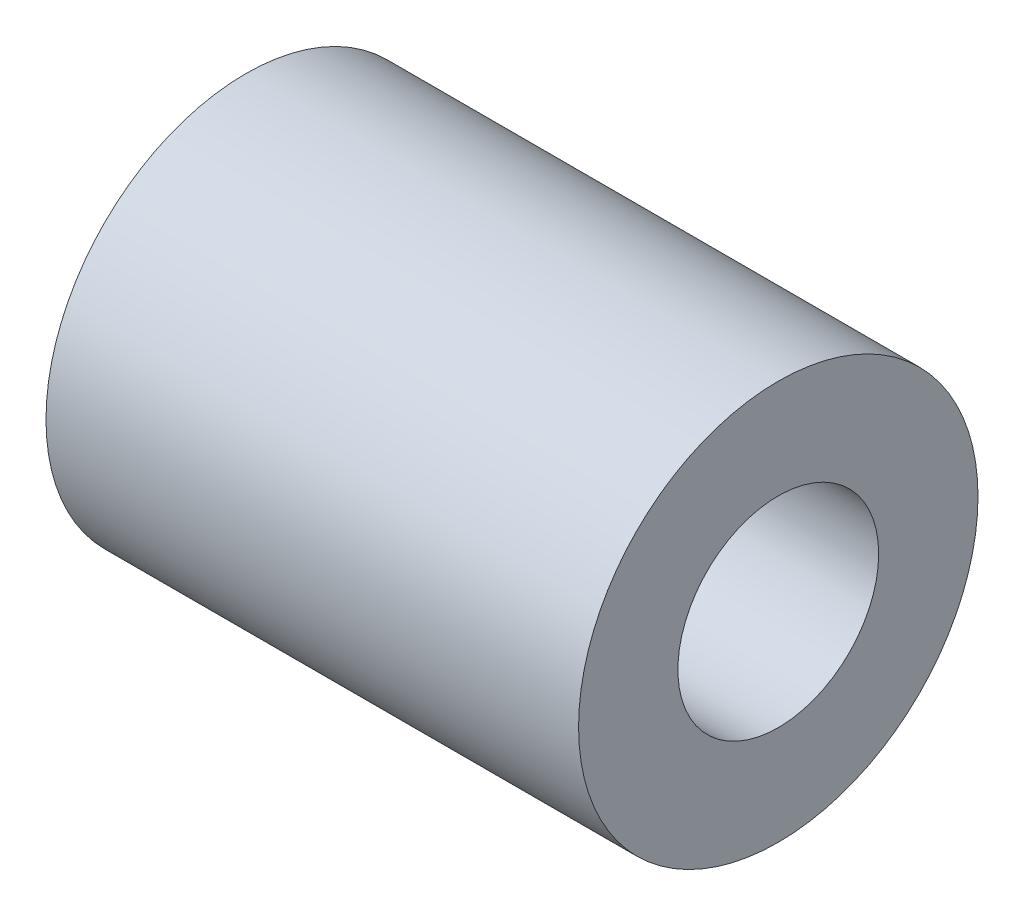
from build123d import *

# Parameters (mm, degrees)
SKETCH1_R           = 9.525
SKETCH1_R_2         = 4.7879
BOSS_EXTRUDE1_DEPTH = 25.4


with BuildPart() as part:
    # Sketch1 → Boss-Extrude1 (new body)
    with BuildSketch(Plane(origin=(0, 0, 0), x_dir=(0, 0, -1), z_dir=(1, 0, 0))):
        Circle(SKETCH1_R)
        Circle(SKETCH1_R_2, mode=Mode.SUBTRACT)
    extrude(amount=BOSS_EXTRUDE1_DEPTH)


solid = part.part
